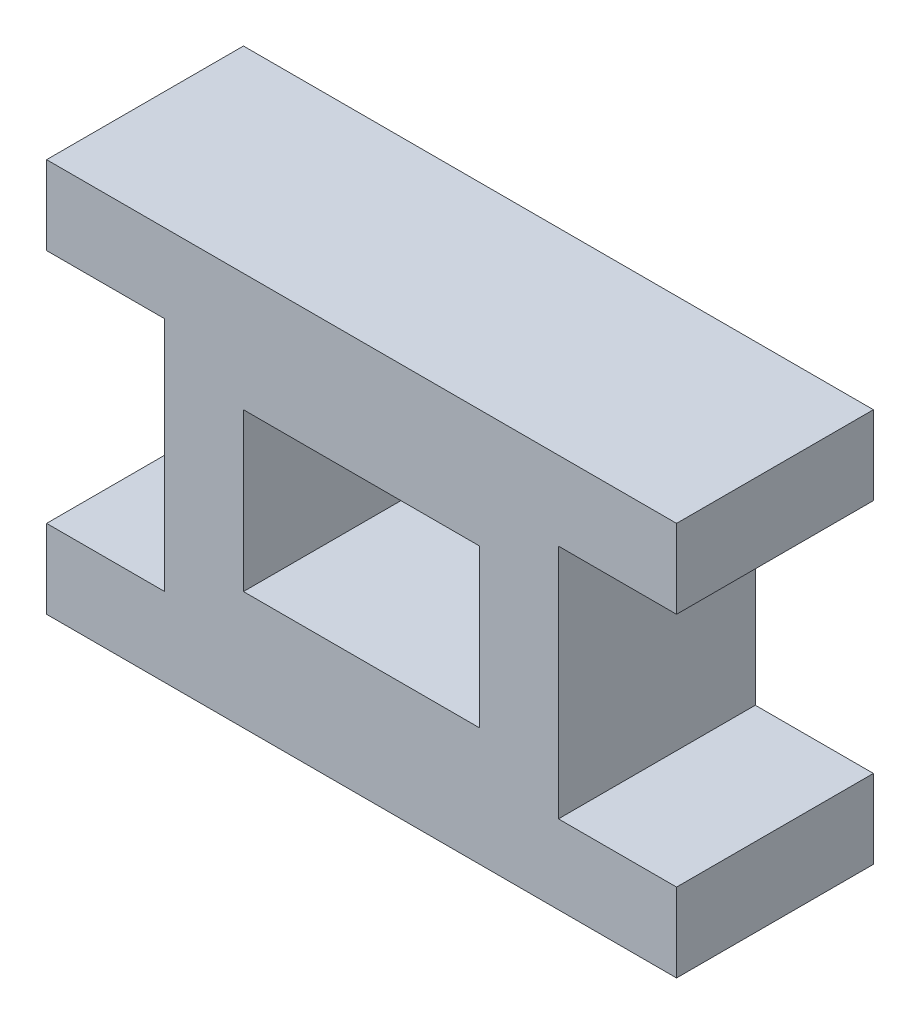
from build123d import *

# Parameters (mm, degrees)
SKETCH1_W           = 30
SKETCH1_H           = 20
BOSS_EXTRUDE1_DEPTH = 25


with BuildPart() as part:
    # Sketch1 → Boss-Extrude1 (new body)
    with BuildSketch(Plane.XY):
        Polygon((-40, -21.936936628), (40, -21.936936628), (40, -11.936936628), (25, -11.936936628), (25, 18.063063372), (40, 18.063063372), (40, 28.063063372), (-40, 28.063063372), (-40, 18.063063372), (-25, 18.063063372), (-25, -11.936936628), (-40, -11.936936628), align=None)
        with Locations((0, 3.063063372)):
            Rectangle(SKETCH1_W, SKETCH1_H, mode=Mode.SUBTRACT)
    extrude(amount=BOSS_EXTRUDE1_DEPTH)


solid = part.part
